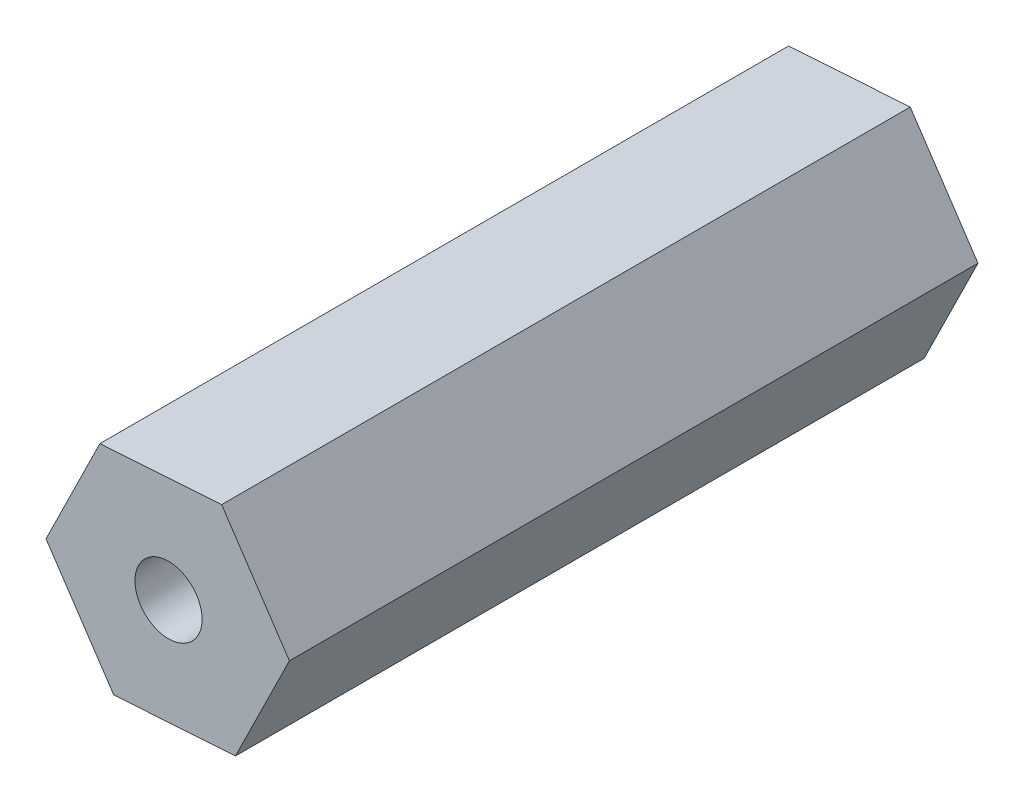
from build123d import *

# Parameters (mm, degrees)
BOSS_EXTRUDE1_DEPTH = 41.402
SKETCH2_R           = 2.0193
CUT_EXTRUDE2_DEPTH  = 12.7
SKETCH3_R           = 1.842835094
CUT_EXTRUDE7_DEPTH  = 12.7


with BuildPart() as part:
    # Sketch1 → Boss-Extrude1 (new body)
    with BuildSketch(Plane.XY):
        Polygon((3.242368481, 6.576502107), (-4.074233653, 6.096224526), (-7.316602133, -0.480277581), (-3.242368481, -6.576502107), (4.074233653, -6.096224526), (7.316602133, 0.480277581), align=None)
    extrude(amount=BOSS_EXTRUDE1_DEPTH)

    # Sketch2 → Cut-Extrude2 (cut)
    with BuildSketch(Plane.XY.offset(41.402)):
        with Locations((0.049397867, 0.013636683)):
            Circle(SKETCH2_R)
    extrude(amount=-CUT_EXTRUDE2_DEPTH, mode=Mode.SUBTRACT)

    # Sketch3 → Cut-Extrude7 (cut)
    with BuildSketch(Plane(origin=(0, 0, 0), x_dir=(-1, 0, 0), z_dir=(0, 0, -1))):
        with Locations((0.049397867, -0.003242583)):
            Circle(SKETCH3_R)
    extrude(amount=-CUT_EXTRUDE7_DEPTH, mode=Mode.SUBTRACT)


solid = part.part
